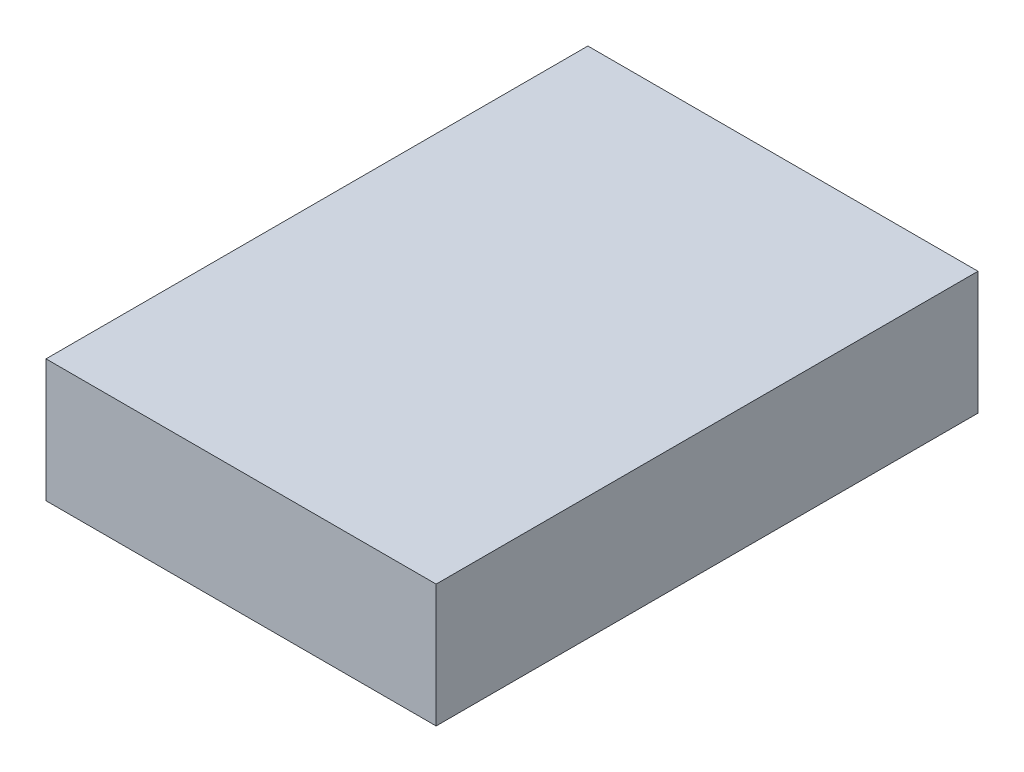
from build123d import *

# Parameters (mm, degrees)
SKETCH1_W           = 18
SKETCH1_H           = 25
BOSS_EXTRUDE1_DEPTH = 5.67


with BuildPart() as part:
    # Sketch1 → Boss-Extrude1 (new body)
    with BuildSketch(Plane(origin=(0, 0, 0), x_dir=(1, 0, 0), z_dir=(0, 1, 0))):
        with Locations((0.355990854, 0.151358288)):
            Rectangle(SKETCH1_W, SKETCH1_H)
    extrude(amount=BOSS_EXTRUDE1_DEPTH)


solid = part.part
